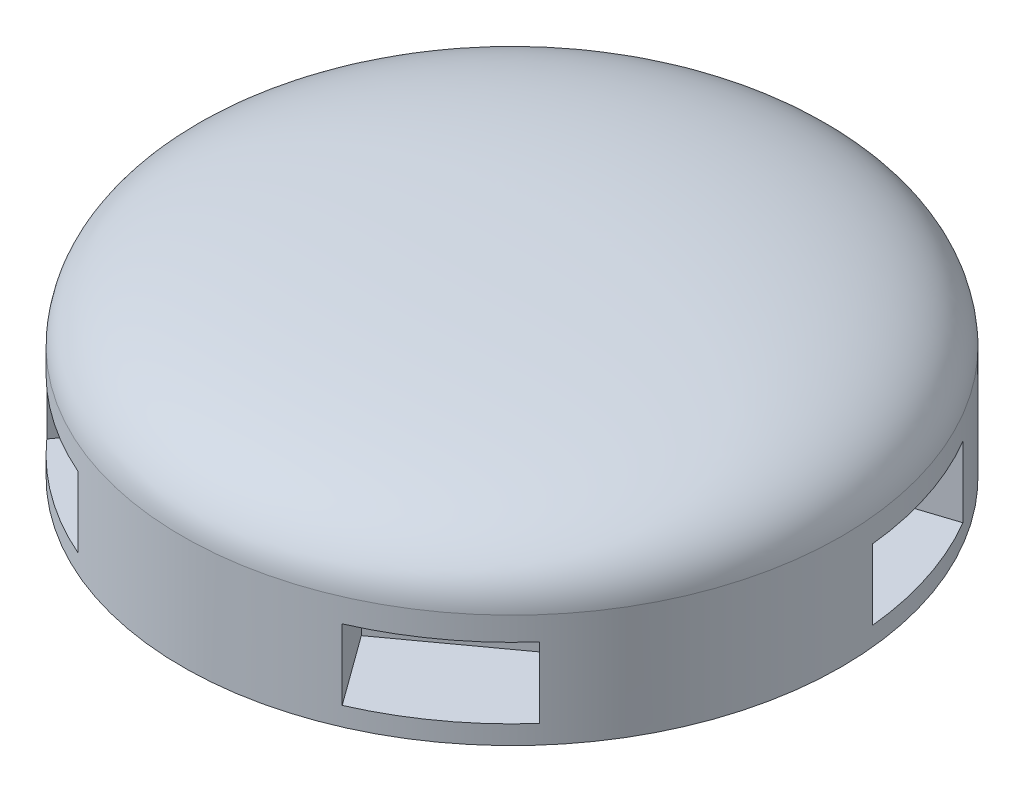
from build123d import *

# Parameters (mm, degrees)
ESQUISSE3_W             = 15
ESQUISSE3_H             = 20
ENL_V_MAT_EXTRU_1_DEPTH = 7.5
ESQUISSE4_R             = 35
BOSS_EXTRU_1_DEPTH      = 2


with BuildPart() as part:
    # Esquisse2 → Révolution1 (revolve)
    with BuildSketch(Plane.XY):
        with BuildLine():
            Line((0, 20), (0, 0))
            Line((0, 0), (35, 0))
            Line((35, 0), (35, 10))
            add(Edge.make_bspline(
                [(0, 20), (32.349399846, 20), (34.80179319, 13.431096766), (35, 10)],
                knots=[0, 0, 0, 0, 1, 1, 1, 1], degree=3))
        make_face()
    revolve(axis=Axis((0, 20, 0), (0, -1, 0)))

    # Esquisse3 → Enlèv. mat.-Extru.1 (cut)
    with BuildSketch(Plane.XZ):
        with Locations((0, -35)):
            Rectangle(ESQUISSE3_W, ESQUISSE3_H)
        Polygon((-45.115170691, -6.772840875), (-26.094040365, -0.592500987), (-21.45878545, -14.858348732), (-40.479915775, -21.038688619), align=None)
        Polygon((-20.382708895, 40.814154139), (-8.627003849, 24.633814252), (-20.762258765, 15.817035467), (-32.517963811, 31.997375355), align=None)
        Polygon((32.517963811, 31.997375355), (20.762258765, 15.817035467), (8.627003849, 24.633814252), (20.382708895, 40.814154139), align=None)
        Polygon((40.479915775, -21.038688619), (21.45878545, -14.858348732), (26.094040365, -0.592500987), (45.115170691, -6.772840875), align=None)
    extrude(amount=-ENL_V_MAT_EXTRU_1_DEPTH, mode=Mode.SUBTRACT)

    # Esquisse4 → Boss.-Extru.1 (add)
    with BuildSketch(Plane.XZ):
        Circle(ESQUISSE4_R)
    extrude(amount=BOSS_EXTRU_1_DEPTH)


solid = part.part
